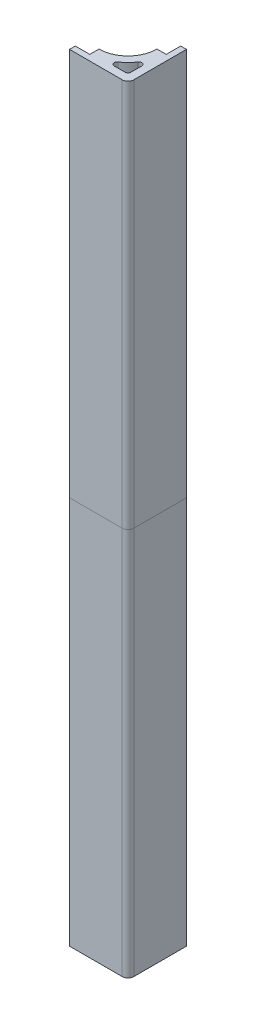
from build123d import *

# Parameters (mm, degrees)
BOSS_EXTRUDE1_DEPTH = 133.95
SHELL1_T            = -2.75
FILLET1_R           = 1


with BuildPart() as part:
    # Sketch1 → Boss-Extrude1 (new body, symmetric)
    with BuildSketch(Plane(origin=(0, 0, 0), x_dir=(1, 0, 0), z_dir=(0, 1, 0))):
        with BuildLine():
            Line((-5.175, 15.175), (-2, 15.175))
            Line((-2, 15.175), (-2, 20.175))
            Line((-2, 20.175), (0, 20.175))
            Line((0, 20.175), (0, 2))
            ThreePointArc((0, 2), (-0.585786438, 0.585786438), (-2, 0))
            Line((-2, 0), (-20.175, 0))
            Line((-20.175, 0), (-20.175, 2))
            Line((-20.175, 2), (-15.175, 2))
            Line((-15.175, 2), (-15.175, 5.175))
            ThreePointArc((-15.175, 5.175), (-8.103932188, 8.103932188), (-5.175, 15.175))
        make_face()
    extrude(amount=BOSS_EXTRUDE1_DEPTH, both=True)

    # Shell1
    shell1_openings = [part.faces().sort_by_distance(p)[0] for p in [
        (-7.938971863, 133.95, -7.938971863),
        (-7.938971863, -133.95, -7.938971863),
    ]]
    offset(amount=SHELL1_T, openings=shell1_openings)

    # Fillet1
    fillet1_edges = [part.edges().sort_by_distance(p)[0] for p in [
        (-2.75, 0, -2.75),
        (-2.75, 0, -12.3146023),
        (-12.3146023, 0, -2.75),
    ]]
    fillet(fillet1_edges, radius=FILLET1_R)


with BuildPart() as body_2:
    # Split1: the piece on the far side of the plane
    add(part.part)
    split(bisect_by=Plane.ZX, keep=Keep.BOTTOM)


with BuildPart() as part_1:
    add(part.part)

    # Split1
    split(bisect_by=Plane.ZX, keep=Keep.TOP)


solid = Compound([body_2.part, part_1.part])
